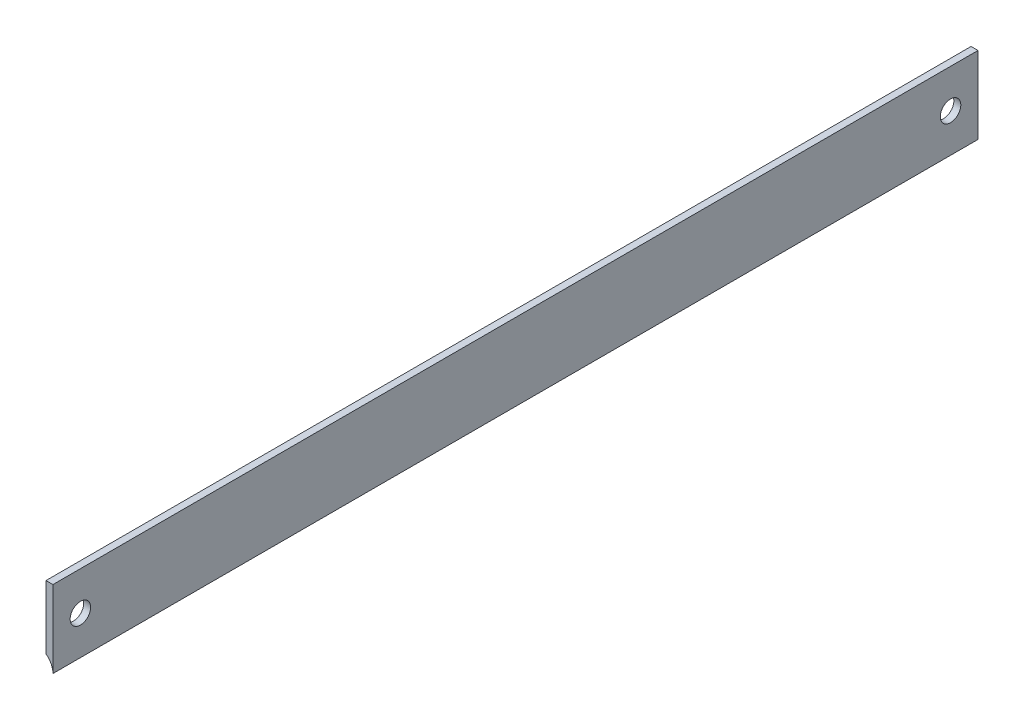
from build123d import *

# Parameters (mm, degrees)
BOSS_EXTRUDE2_DEPTH     = 304.8
F_1_4_CLEARANCE_HOLE2_D = 6.7564


with BuildPart() as part:
    # Sketch1 → Boss-Extrude2 (new body)
    with BuildSketch(Plane.XY):
        with BuildLine():
            Line((-1.143, -8.256814656), (-1.143, 12.7))
            Line((-1.143, 12.7), (1.143, 12.7))
            Line((1.143, 12.7), (1.143, -12.7))
            ThreePointArc((1.143, -12.7), (0.537985791, -10.201615922), (-1.143, -8.256814656))
        make_face()
    extrude(amount=BOSS_EXTRUDE2_DEPTH)

    # 1/4 Clearance Hole2 (through all)
    with Locations(Plane.ZY.offset(1.143)):
        with Locations((9.050000188, 0), (295.749999812, 0)):
            Hole(F_1_4_CLEARANCE_HOLE2_D / 2)


solid = part.part
